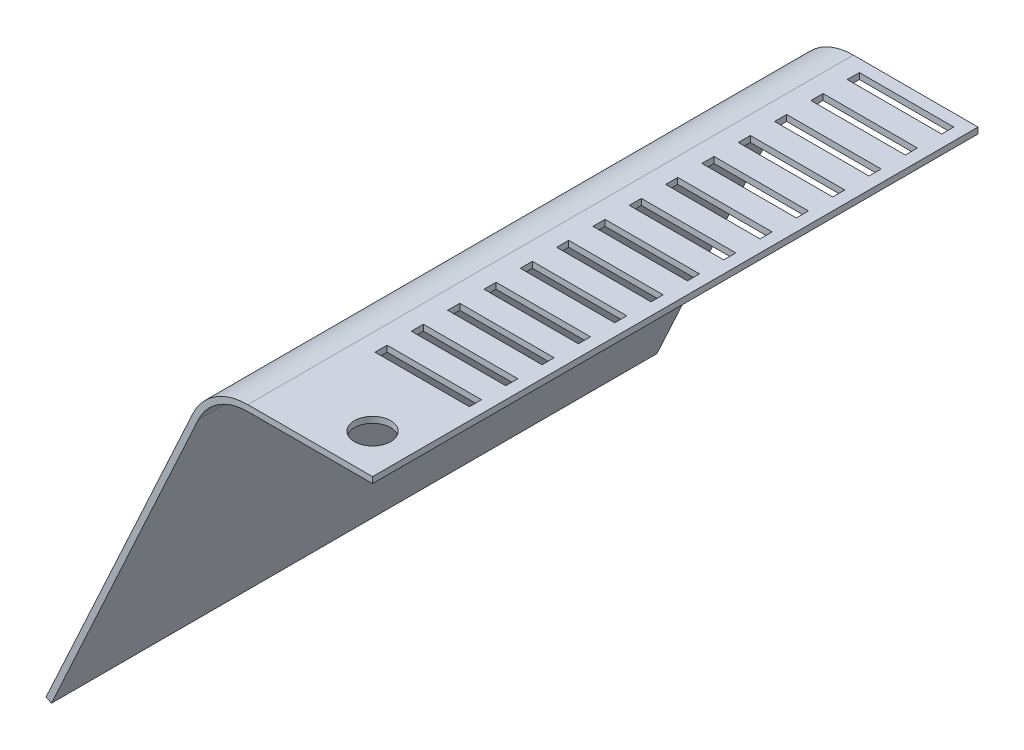
from build123d import *

# Parameters (mm, degrees)
EXTRUDE_THIN1_DEPTH = 500
SKETCH2_R           = 30
SKETCH2_W           = 155.95
SKETCH2_H           = 20
CUT_EXTRUDE1_DEPTH  = 590.213534275


with BuildPart() as part:
    # Sketch1 → Extrude-Thin1 (new body, symmetric)
    with BuildSketch(Plane.XY):
        with BuildLine():
            Line((0, 0), (242.546822959, 526.850110252))
            ThreePointArc((242.546822959, 526.850110252), (279.447169226, 569.239298377), (333.383048865, 585.0316925))
            Line((333.383048865, 585.0316925), (539.333048865, 585.0316925))
            Line((539.333048865, 585.0316925), (539.333048865, 575.0316925))
            Line((539.333048865, 575.0316925), (333.383048865, 575.0316925))
            ThreePointArc((333.383048865, 575.0316925), (284.84075719, 560.81853779), (251.63044555, 522.668268477))
            Line((251.63044555, 522.668268477), (9.083622591, -4.181841775))
            Line((9.083622591, -4.181841775), (0, 0))
        make_face()
    extrude(amount=EXTRUDE_THIN1_DEPTH, both=True)

    # Sketch2 → Cut-Extrude1 (cut, through all)
    with BuildSketch(Plane(origin=(0, 585.0316925, 0), x_dir=(1, 0, 0), z_dir=(0, 1, 0))):
        with Locations((474.333048865, -435)):
            Circle(SKETCH2_R)
        with Locations((441.358048865, 470)):
            Rectangle(SKETCH2_W, SKETCH2_H)
        with Locations((441.358048865, 410)):
            Rectangle(SKETCH2_W, SKETCH2_H)
        with Locations((441.358048865, 350)):
            Rectangle(SKETCH2_W, SKETCH2_H)
        with Locations((441.358048865, 290)):
            Rectangle(SKETCH2_W, SKETCH2_H)
        with Locations((441.358048865, 230)):
            Rectangle(SKETCH2_W, SKETCH2_H)
        with Locations((441.358048865, 170)):
            Rectangle(SKETCH2_W, SKETCH2_H)
        with Locations((441.358048865, 110)):
            Rectangle(SKETCH2_W, SKETCH2_H)
        with Locations((441.358048865, 50)):
            Rectangle(SKETCH2_W, SKETCH2_H)
        with Locations((441.358048865, -10)):
            Rectangle(SKETCH2_W, SKETCH2_H)
        with Locations((441.358048865, -70)):
            Rectangle(SKETCH2_W, SKETCH2_H)
        with Locations((441.358048865, -130)):
            Rectangle(SKETCH2_W, SKETCH2_H)
        with Locations((441.358048865, -190)):
            Rectangle(SKETCH2_W, SKETCH2_H)
        with Locations((441.358048865, -250)):
            Rectangle(SKETCH2_W, SKETCH2_H)
        with Locations((441.358048865, -310)):
            Rectangle(SKETCH2_W, SKETCH2_H)
    extrude(amount=-CUT_EXTRUDE1_DEPTH, mode=Mode.SUBTRACT)


solid = part.part
